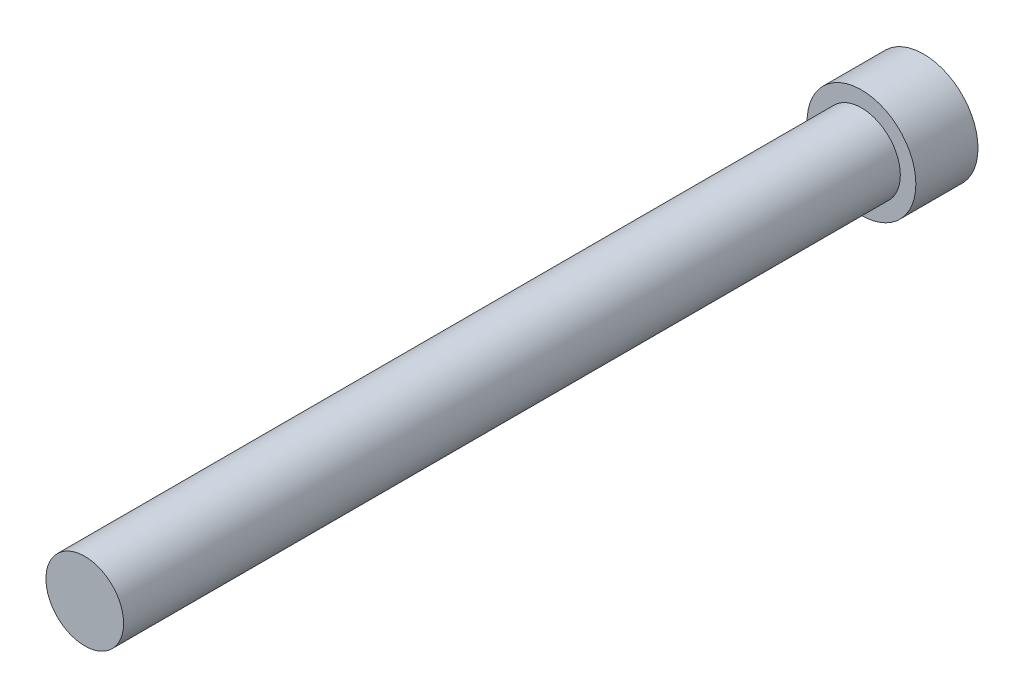
from build123d import *

# Parameters (mm, degrees)
SKETCH1_R         = 4.445
EXTRUDE1_DEPTH    = 68.58
SKETCH2_OUTSIDE_W = 24.834
SKETCH2_OUTSIDE_H = 24.834
SKETCH2_OUTSIDE_R = 3.175
EXTRUDE2_DEPTH    = 63.5


with BuildPart() as part:
    # Sketch1 → Extrude1 (new body)
    with BuildSketch(Plane.XY):
        Circle(SKETCH1_R)
    extrude(amount=EXTRUDE1_DEPTH)

    # Sketch2 outside → Extrude2 (cut)
    with BuildSketch(Plane.XY.offset(68.58)):
        Rectangle(SKETCH2_OUTSIDE_W, SKETCH2_OUTSIDE_H)
        Circle(SKETCH2_OUTSIDE_R, mode=Mode.SUBTRACT)
    extrude(amount=-EXTRUDE2_DEPTH, mode=Mode.SUBTRACT)


solid = part.part
